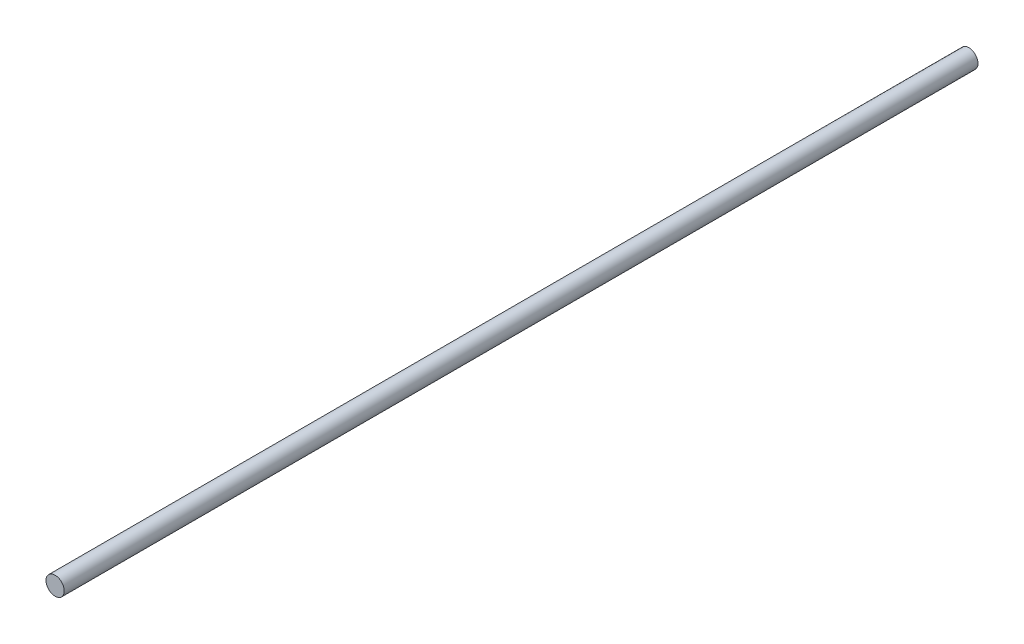
from build123d import *

# Parameters (mm, degrees)
SKETCH_1_R      = 4
EXTRUDE_1_DEPTH = 400


with BuildPart() as part:
    # 草图1 → 凸台-拉伸1 (new body)
    with BuildSketch(Plane.XY):
        Circle(SKETCH_1_R)
    extrude(amount=EXTRUDE_1_DEPTH)


solid = part.part
